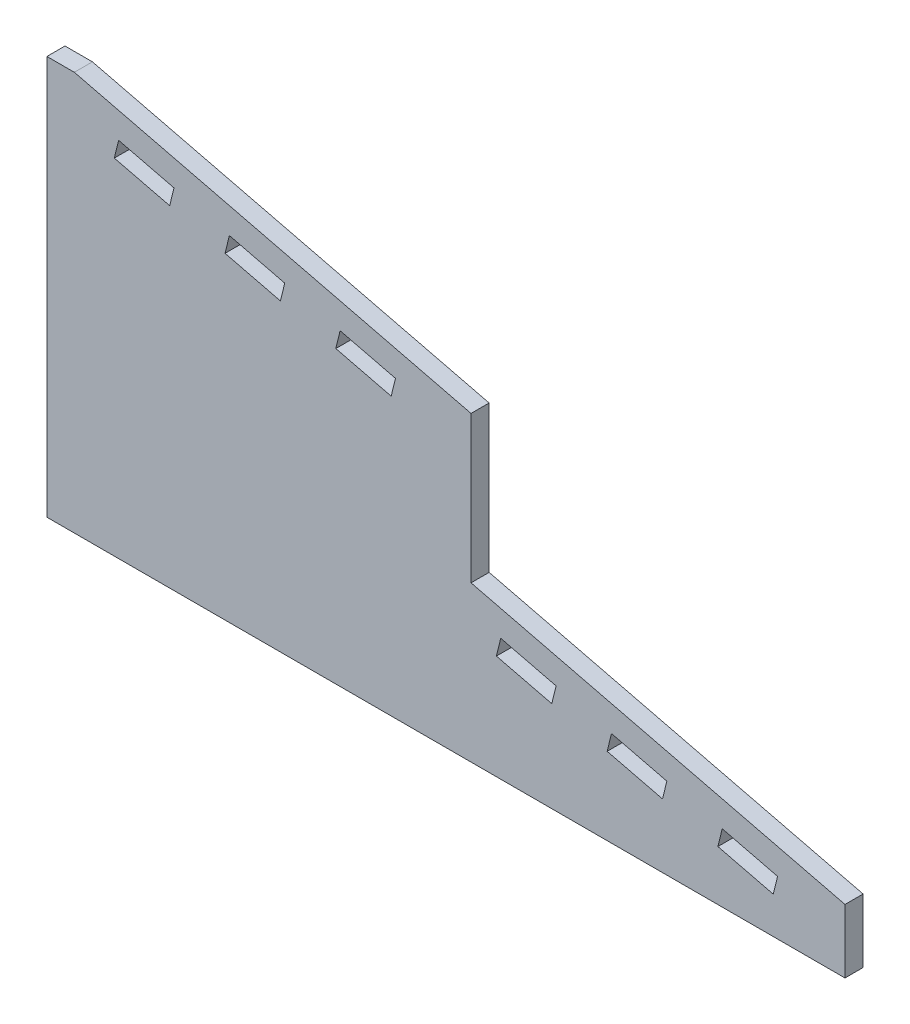
from build123d import *

# Parameters (mm, degrees)
SKETCH1_W           = 140
SKETCH1_H           = 70
BOSS_EXTRUDE1_DEPTH = 3.175
CUT_EXTRUDE1_DEPTH  = 4.175
CUT_EXTRUDE2_DEPTH  = 4.175


with BuildPart() as part:
    # Sketch1 → Boss-Extrude1 (new body)
    with BuildSketch(Plane.XY):
        with Locations((70, 35)):
            Rectangle(SKETCH1_W, SKETCH1_H)
    extrude(amount=BOSS_EXTRUDE1_DEPTH)

    # Sketch4 → Cut-Extrude1 (cut, through all)
    with BuildSketch(Plane.XY.offset(3.175)):
        Polygon((12.579717356, 63.555712168), (11.824972296, 60.471723696), (21.538321814, 58.094573903), (22.293066874, 61.178562375), align=None)
        Polygon((41.71976591, 56.424262788), (32.006416392, 58.801412581), (31.251671332, 55.71742411), (40.96502085, 53.340274316), align=None)
        Polygon((61.146464946, 51.669963201), (51.433115428, 54.047112995), (50.678370368, 50.963124523), (60.391719886, 48.585974729), align=None)
        Polygon((118.461678186, 11.905426097), (128.175027704, 9.528276304), (127.420282644, 6.444287832), (117.706933126, 8.821437625), align=None)
        Polygon((98.28023409, 13.575737212), (99.03497915, 16.659725684), (108.748328668, 14.28257589), (107.993583608, 11.198587419), align=None)
        Polygon((78.853535054, 18.330036799), (79.608280114, 21.414025271), (89.321629632, 19.036875477), (88.566884572, 15.952887005), align=None)
    extrude(amount=-CUT_EXTRUDE1_DEPTH, mode=Mode.SUBTRACT)

    # Sketch5 → Cut-Extrude2 (cut, through all)
    with BuildSketch(Plane.XY.offset(3.175)):
        Polygon((4.809647436, 70), (74.397727118, 52.969696608), (74.397727118, 27.23192206), (140, 11.177065891), (140, 70), align=None)
    extrude(amount=-CUT_EXTRUDE2_DEPTH, mode=Mode.SUBTRACT)


solid = part.part
